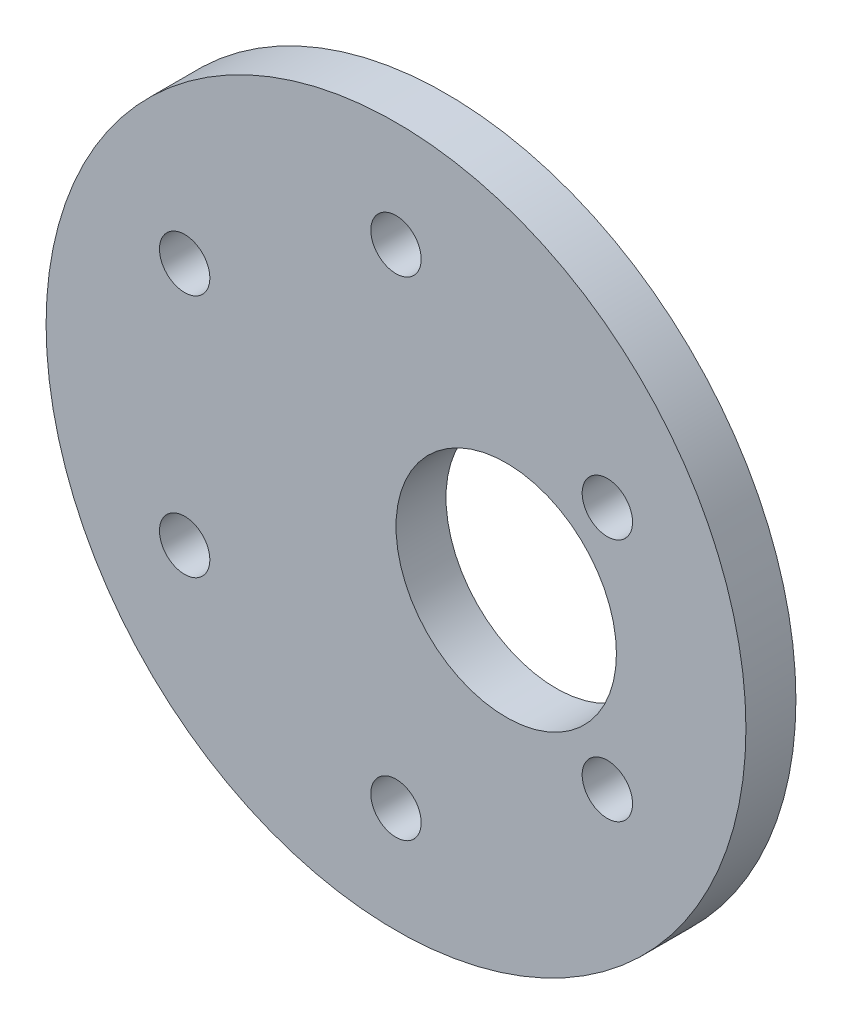
from build123d import *

# Parameters (mm, degrees)
SKETCH1_R                = 22.225
BOSS_EXTRUDE1_DEPTH      = 3.175
M3_CLEARANCE_HOLE1_D     = 3.2
M3_CLEARANCE_HOLE1_DEPTH = 3.175
CUT_EXTRUDE1_REACH       = 5.175
SKETCH4_R                = 7


with BuildPart() as part:
    # Sketch1 → Boss-Extrude1 (new body)
    with BuildSketch(Plane.XY):
        Circle(SKETCH1_R)
    extrude(amount=BOSS_EXTRUDE1_DEPTH)

    # M3 Clearance Hole1
    with Locations(Plane.XY.offset(3.175)):
        with Locations((-13.423393759, 7.75), (0, 15.5), (13.423393759, 7.75), (13.423393759, -7.75), (0, -15.5), (-13.423393759, -7.75)):
            Hole(M3_CLEARANCE_HOLE1_D / 2, depth=M3_CLEARANCE_HOLE1_DEPTH)

    # Sketch4 → Cut-Extrude1 (cut, up to next)
    with BuildSketch(Plane.XY.offset(3.175), mode=Mode.PRIVATE) as cut_extrude1_sk1:
        with Locations((7, 0)):
            Circle(SKETCH4_R)
    cut_extrude1_tool1 = extrude(cut_extrude1_sk1.sketch, amount=-CUT_EXTRUDE1_REACH, mode=Mode.PRIVATE) & part.part
    add(cut_extrude1_tool1.solids().sort_by_distance((7, 0, 3.175))[0], mode=Mode.SUBTRACT)


solid = part.part
